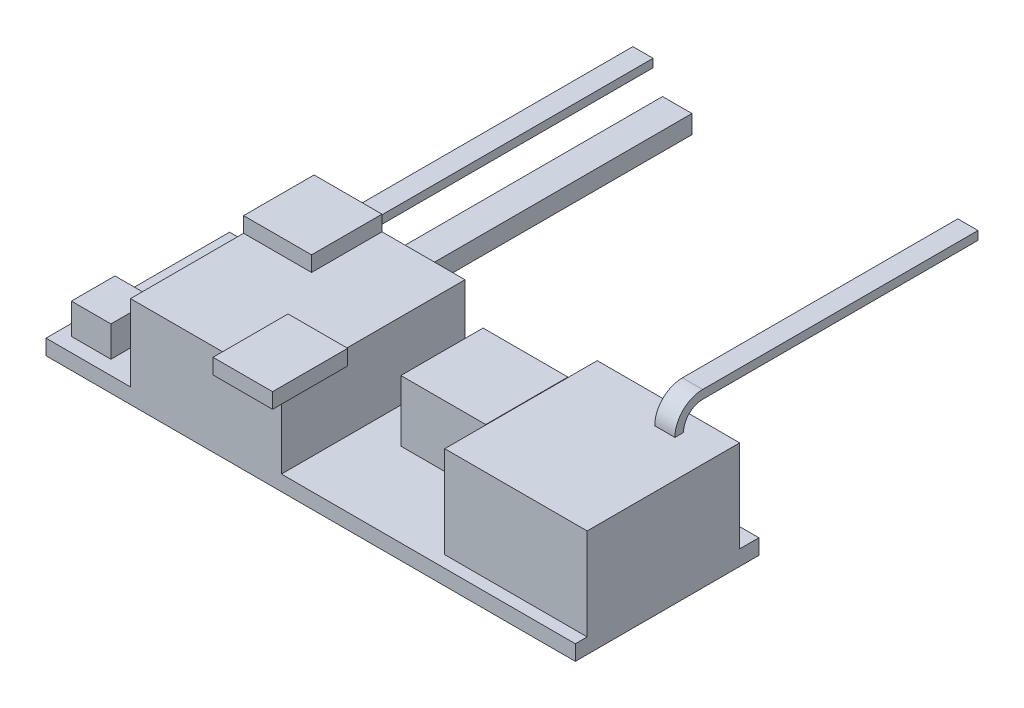
from build123d import *

# Parameters (mm, degrees)
SKETCH1_W           = 219.71
SKETCH1_H           = 76.2
BOSS_EXTRUDE1_DEPTH = 6.35
SKETCH2_W           = 16.419540588
SKETCH2_H           = 18.090055728
BOSS_EXTRUDE2_DEPTH = 12.7
SKETCH3_W           = 62.648941473
SKETCH3_H           = 76.2
BOSS_EXTRUDE3_DEPTH = 31.75
SKETCH4_W           = 28.19846857
SKETCH4_H           = 29.245485709
SKETCH4_W_2         = 24.722904469
SKETCH4_H_2         = 31.160798061
BOSS_EXTRUDE4_DEPTH = 6.35
SKETCH5_W           = 35.218039436
SKETCH5_H           = 34.118830673
BOSS_EXTRUDE5_DEPTH = 25.4
SKETCH6_W           = 59.112851394
SKETCH6_H           = 63.314217613
BOSS_EXTRUDE6_DEPTH = 38.1
SKETCH7_W           = 8.382
SKETCH7_H           = 3.556
REVOLVE1_ANGLE      = 90
SKETCH8_W           = 8.382
SKETCH8_H           = 3.556
BOSS_EXTRUDE7_DEPTH = 114.3
SKETCH9_W           = 8.382
SKETCH9_H           = 3.429
BOSS_EXTRUDE8_DEPTH = 114.3
SKETCH10_W          = 12.202797109
SKETCH10_H          = 7.62
BOSS_EXTRUDE9_DEPTH = 114.3


with BuildPart() as part:
    # Sketch1 → Boss-Extrude1 (new body)
    with BuildSketch(Plane(origin=(0, 0, 0), x_dir=(1, 0, 0), z_dir=(0, 1, 0))):
        with Locations((30.217434145, 13.693097702)):
            Rectangle(SKETCH1_W, SKETCH1_H)
    extrude(amount=BOSS_EXTRUDE1_DEPTH)

    # Sketch2 → Boss-Extrude2 (add)
    with BuildSketch(Plane(origin=(0, 6.35, 0), x_dir=(1, 0, 0), z_dir=(0, 1, 0))):
        with Locations((-66.781056723, -9.475333681)):
            Rectangle(SKETCH2_W, SKETCH2_H)
    extrude(amount=BOSS_EXTRUDE2_DEPTH)

    # Sketch3 → Boss-Extrude3 (add)
    with BuildSketch(Plane(origin=(0, 6.35, 0), x_dir=(1, 0, 0), z_dir=(0, 1, 0))):
        with Locations((-13.243395753, 13.693097702)):
            Rectangle(SKETCH3_W, SKETCH3_H)
    extrude(amount=BOSS_EXTRUDE3_DEPTH)

    # Sketch4 → Boss-Extrude4 (add)
    with BuildSketch(Plane(origin=(0, 38.1, 0), x_dir=(1, 0, 0), z_dir=(0, 1, 0))):
        with Locations((-30.468632204, 37.170354848)):
            Rectangle(SKETCH4_W, SKETCH4_H)
        with Locations((12.361452235, -19.146202813)):
            Rectangle(SKETCH4_W_2, SKETCH4_H_2)
    extrude(amount=BOSS_EXTRUDE4_DEPTH)

    # Sketch5 → Boss-Extrude5 (add)
    with BuildSketch(Plane(origin=(0, 6.35, 0), x_dir=(1, 0, 0), z_dir=(0, 1, 0))):
        with Locations((50.4602019, 27.468454075)):
            Rectangle(SKETCH5_W, SKETCH5_H)
    extrude(amount=BOSS_EXTRUDE5_DEPTH)

    # Sketch6 → Boss-Extrude6 (add)
    with BuildSketch(Plane(origin=(0, 6.35, 0), x_dir=(1, 0, 0), z_dir=(0, 1, 0))):
        with Locations((110.516008448, 12.157062675)):
            Rectangle(SKETCH6_W, SKETCH6_H)
    extrude(amount=BOSS_EXTRUDE6_DEPTH)

    # Sketch7 → Revolve1 (revolve)
    with BuildSketch(Plane(origin=(0, 44.45, 0), x_dir=(1, 0, 0), z_dir=(0, 1, 0))):
        with Locations((120.503604839, 34.09026034)):
            Rectangle(SKETCH7_W, SKETCH7_H)
    revolve(axis=Axis((80.959582751, 44.45, -43.814171481), (-1, 0, 0)), revolution_arc=REVOLVE1_ANGLE)

    # Sketch8 → Boss-Extrude7 (add)
    with BuildSketch(Plane(origin=(0, 0, -43.814171481), x_dir=(-1, 0, 0), z_dir=(0, 0, -1))):
        with Locations((-120.503604839, 54.173911141)):
            Rectangle(SKETCH8_W, SKETCH8_H)
    extrude(amount=BOSS_EXTRUDE7_DEPTH)

    # Sketch9 → Boss-Extrude8 (add)
    with BuildSketch(Plane(origin=(0, 0, -51.793097702), x_dir=(-1, 0, 0), z_dir=(0, 0, -1))):
        with Locations((22.339963583, 40.733802784)):
            Rectangle(SKETCH9_W, SKETCH9_H)
    extrude(amount=BOSS_EXTRUDE8_DEPTH)

    # Sketch10 → Boss-Extrude9 (add)
    with BuildSketch(Plane(origin=(0, 0, -51.793097702), x_dir=(-1, 0, 0), z_dir=(0, 0, -1))):
        with Locations((8.119417051, 26.849119085)):
            Rectangle(SKETCH10_W, SKETCH10_H)
    extrude(amount=BOSS_EXTRUDE9_DEPTH)


solid = part.part
